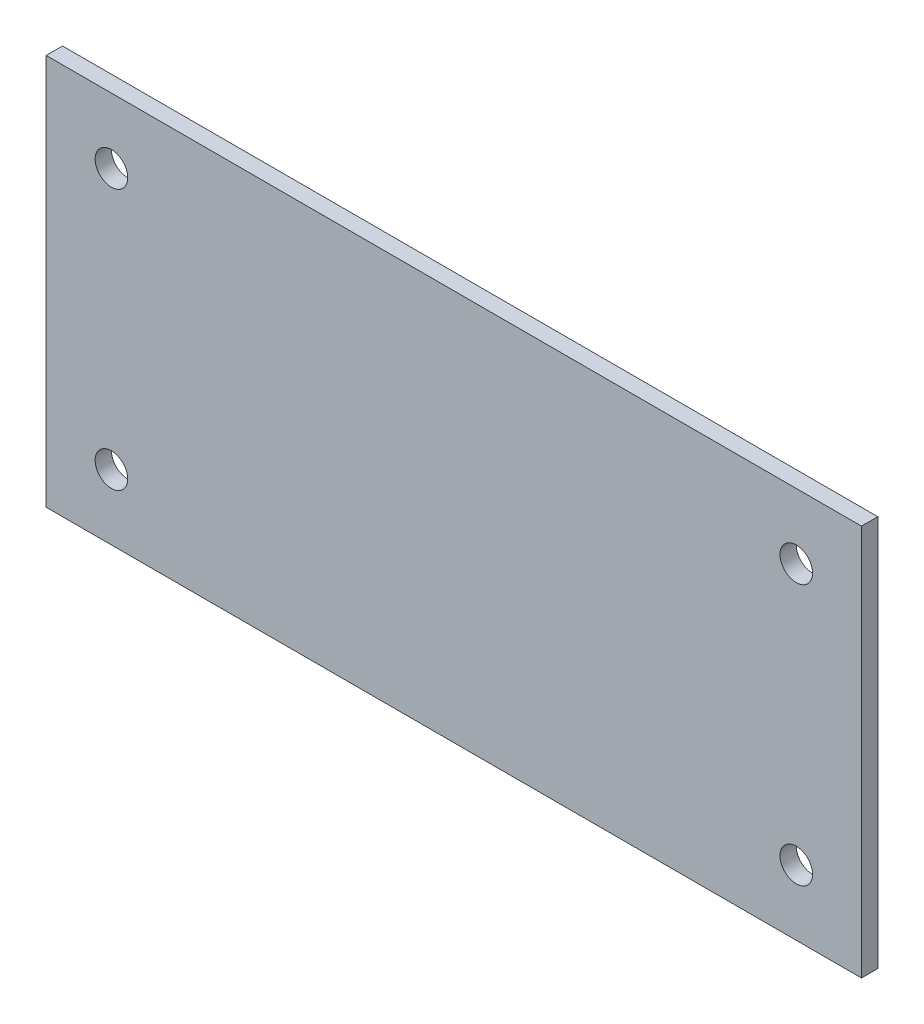
from build123d import *

# Parameters (mm, degrees)
SKETCH_1_W      = 250
SKETCH_1_H      = 120
SKETCH_1_R      = 5
EXTRUDE_1_DEPTH = 5


with BuildPart() as part:
    # 草图1 → 凸台-拉伸1 (new body)
    with BuildSketch(Plane.XY):
        Rectangle(SKETCH_1_W, SKETCH_1_H)
        with Locations((-105, 40)):
            Circle(SKETCH_1_R, mode=Mode.SUBTRACT)
        with Locations((105, 40)):
            Circle(SKETCH_1_R, mode=Mode.SUBTRACT)
        with Locations((105, -40)):
            Circle(SKETCH_1_R, mode=Mode.SUBTRACT)
        with Locations((-105, -40)):
            Circle(SKETCH_1_R, mode=Mode.SUBTRACT)
    extrude(amount=EXTRUDE_1_DEPTH)


solid = part.part
